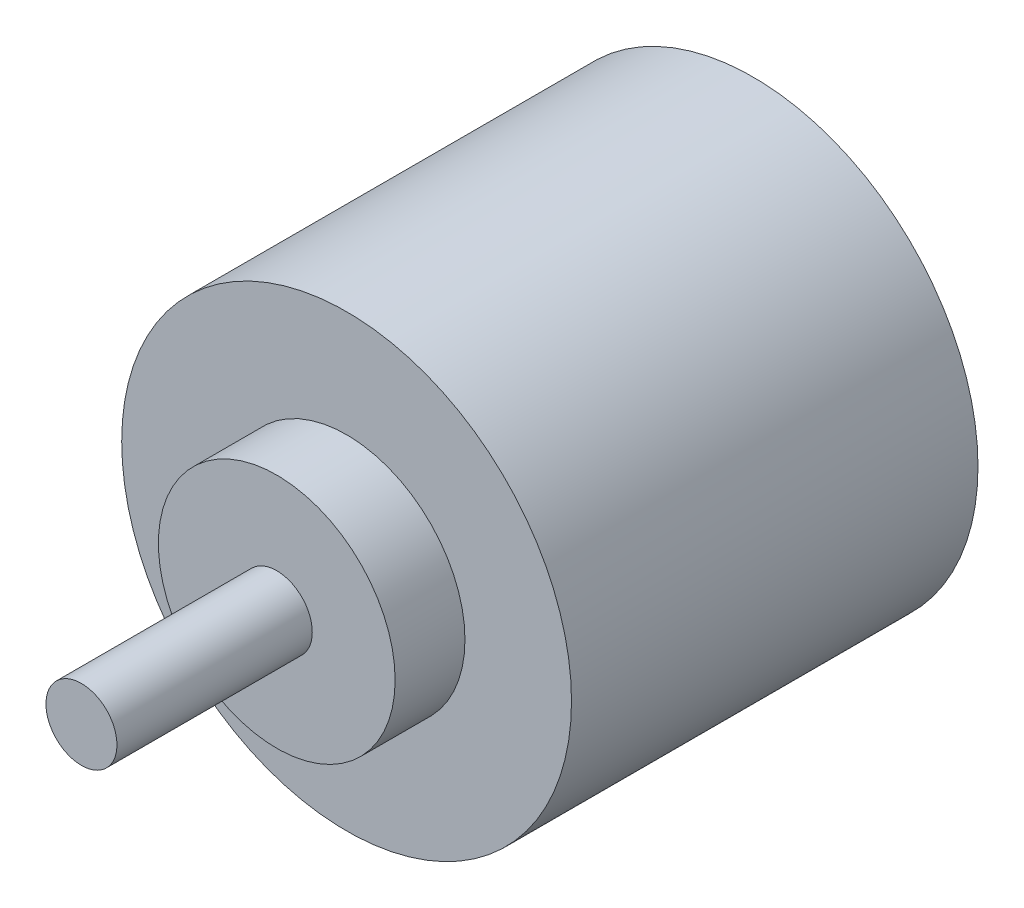
from build123d import *

# Parameters (mm, degrees)
SKETCH1_R           = 19
BOSS_EXTRUDE1_DEPTH = 34.34
SKETCH2_R           = 10
BOSS_EXTRUDE2_DEPTH = 5.9
SKETCH3_R           = 3
BOSS_EXTRUDE3_DEPTH = 16.5


with BuildPart() as part:
    # Sketch1 → Boss-Extrude1 (new body)
    with BuildSketch(Plane.XY):
        Circle(SKETCH1_R)
    extrude(amount=BOSS_EXTRUDE1_DEPTH)

    # Sketch2 → Boss-Extrude2 (add)
    with BuildSketch(Plane.XY.offset(34.34)):
        Circle(SKETCH2_R)
    extrude(amount=BOSS_EXTRUDE2_DEPTH)

    # Sketch3 → Boss-Extrude3 (add)
    with BuildSketch(Plane.XY.offset(40.24)):
        Circle(SKETCH3_R)
    extrude(amount=BOSS_EXTRUDE3_DEPTH)


solid = part.part
